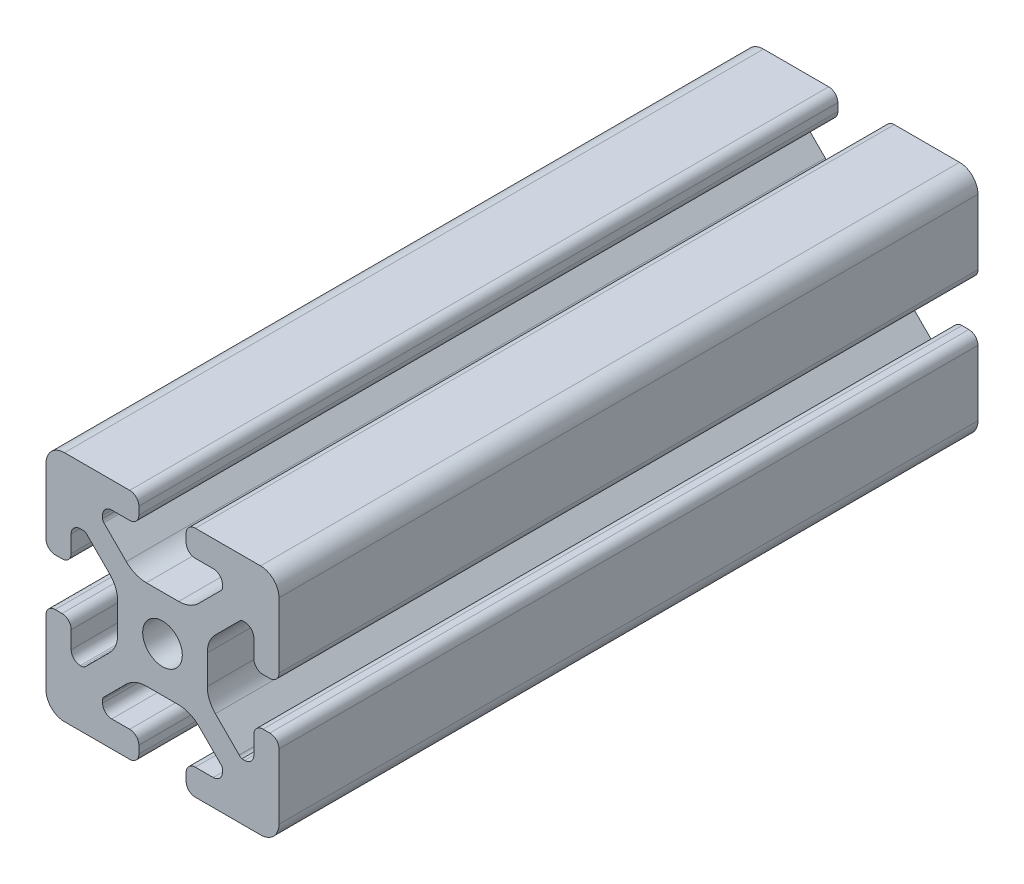
from build123d import *

# Parameters (mm, degrees)
SKETCH1_R      = 3.4
EXTRUDE1_DEPTH = 120


with BuildPart() as part:
    # Sketch1 → Extrude1 (new body)
    with BuildSketch(Plane.XY):
        with BuildLine():
            Line((-8.715, -15.524615034), (-5.63, -15.524615034))
            ThreePointArc((-5.63, -15.524615034), (-4.519842354, -15.984457388), (-4.06, -17.094615034))
            Line((-4.06, -17.094615034), (-4.06, -18.43))
            ThreePointArc((-4.06, -18.43), (-4.519842354, -19.540157646), (-5.63, -20))
            Line((-5.63, -20), (-16.674615034, -20))
            ThreePointArc((-16.674615034, -20), (-18.951578385, -19.194274381), (-20, -17.018368134))
            Line((-20, -17.018368134), (-20, -5.757918808))
            ThreePointArc((-20, -5.757918808), (-19.564709668, -4.603883664), (-18.43, -4.120449326))
            Line((-18.43, -4.120449326), (-17.25, -4.120449326))
            ThreePointArc((-17.25, -4.120449326), (-16.115287682, -4.60388249), (-15.67999625, -5.757919334))
            Line((-15.67999625, -5.757919334), (-15.67999625, -8.715399492))
            ThreePointArc((-15.67999625, -8.715399492), (-15.220153896, -9.825557139), (-14.10999625, -10.285399492))
            Line((-14.10999625, -10.285399492), (-13.816898819, -10.285399492))
            ThreePointArc((-13.816898819, -10.285399492), (-13.526061711, -10.227547119), (-13.279501941, -10.062800646))
            Line((-13.279501941, -10.062800646), (-9.076242789, -5.859541495))
            ThreePointArc((-9.076242789, -5.859541495), (-8.046572221, -4.318530588), (-7.685, -2.500784284))
            Line((-7.685, -2.500784284), (-7.685, 2.500784284))
            ThreePointArc((-7.685, 2.500784284), (-8.046572221, 4.318530588), (-9.076242789, 5.859541495))
            Line((-9.076242789, 5.859541495), (-13.040489136, 9.823787841))
            ThreePointArc((-13.040489136, 9.823787841), (-13.354224618, 10.012729352), (-13.71989919, 10.033001362))
            Line((-13.71989919, 10.033001362), (-14.05520779, 10.044710596))
            ThreePointArc((-14.05520779, 10.044710596), (-15.200613642, 9.605030484), (-15.68, 8.475666998))
            Line((-15.68, 8.475666998), (-15.68, 5.572979049))
            ThreePointArc((-15.68, 5.572979049), (-16.139842354, 4.462821403), (-17.25, 4.002979049))
            Line((-17.25, 4.002979049), (-18.43, 4.002979049))
            ThreePointArc((-18.43, 4.002979049), (-19.540157646, 4.462821403), (-20, 5.572979049))
            Line((-20, 5.572979049), (-20, 13.004526564))
            Line((-20, 13.004526564), (-20, 16.83))
            ThreePointArc((-20, 16.83), (-19.071528496, 19.071528496), (-16.83, 20))
            Line((-16.83, 20), (-5.63, 20))
            ThreePointArc((-5.63, 20), (-4.519842354, 19.540157646), (-4.06, 18.43))
            Line((-4.06, 18.43), (-4.06, 17.094615034))
            ThreePointArc((-4.06, 17.094615034), (-4.519842354, 15.984457388), (-5.63, 15.524615034))
            Line((-5.63, 15.524615034), (-8.715, 15.524615034))
            ThreePointArc((-8.715, 15.524615034), (-9.825157646, 15.06477268), (-10.285, 13.954615034))
            Line((-10.285, 13.954615034), (-10.285, 13.492503602))
            ThreePointArc((-10.285, 13.492503602), (-10.227148445, 13.201664194), (-10.062401154, 12.955102448))
            Line((-10.062401154, 12.955102448), (-6.217092793, 9.109794088))
            ThreePointArc((-6.217092793, 9.109794088), (-4.63891877, 8.055291919), (-2.777335583, 7.685))
            Line((-2.777335583, 7.685), (2.777335583, 7.685))
            ThreePointArc((2.777335583, 7.685), (4.63891877, 8.055291919), (6.217092793, 9.109794088))
            Line((6.217092793, 9.109794088), (10.062401154, 12.955102448))
            ThreePointArc((10.062401154, 12.955102448), (10.227148445, 13.201664194), (10.285, 13.492503602))
            Line((10.285, 13.492503602), (10.285, 13.954615034))
            ThreePointArc((10.285, 13.954615034), (9.825157646, 15.06477268), (8.715, 15.524615034))
            Line((8.715, 15.524615034), (5.63, 15.524615034))
            ThreePointArc((5.63, 15.524615034), (4.519842354, 15.984457388), (4.06, 17.094615034))
            Line((4.06, 17.094615034), (4.06, 18.43))
            ThreePointArc((4.06, 18.43), (4.519842354, 19.540157646), (5.63, 20))
            Line((5.63, 20), (12.979635074, 20))
            Line((12.979635074, 20), (16.83, 20))
            ThreePointArc((16.83, 20), (19.071528496, 19.071528496), (20, 16.83))
            Line((20, 16.83), (20, 13.001098436))
            Line((20, 13.001098436), (20, 5.63))
            ThreePointArc((20, 5.63), (19.540157461, 4.519842693), (18.43, 4.060000526))
            Line((18.43, 4.060000526), (17.24999625, 4.060000526))
            ThreePointArc((17.24999625, 4.060000526), (16.139838603, 4.519842879), (15.67999625, 5.630000526))
            Line((15.67999625, 5.630000526), (15.67999625, 8.715399492))
            ThreePointArc((15.67999625, 8.715399492), (15.220153896, 9.825557139), (14.10999625, 10.285399492))
            Line((14.10999625, 10.285399492), (13.816903094, 10.285399492))
            ThreePointArc((13.816903094, 10.285399492), (13.526063686, 10.227547937), (13.279501941, 10.062800646))
            Line((13.279501941, 10.062800646), (9.076242789, 5.859541495))
            ThreePointArc((9.076242789, 5.859541495), (8.046572221, 4.318530588), (7.685, 2.500784284))
            Line((7.685, 2.500784284), (7.685, -2.500784284))
            ThreePointArc((7.685, -2.500784284), (8.046572221, -4.318530588), (9.076242789, -5.859541495))
            Line((9.076242789, -5.859541495), (13.163657296, -9.946956002))
            ThreePointArc((13.163657296, -9.946956002), (13.35903797, -10.160433474), (13.6200547, -10.285399492))
            Line((13.6200547, -10.285399492), (14.10999625, -10.285399492))
            ThreePointArc((14.10999625, -10.285399492), (15.220153896, -9.825557139), (15.67999625, -8.715399492))
            Line((15.67999625, -8.715399492), (15.67999625, -5.630000526))
            ThreePointArc((15.67999625, -5.630000526), (16.139838603, -4.519842879), (17.24999625, -4.060000526))
            Line((17.24999625, -4.060000526), (18.43, -4.060000526))
            ThreePointArc((18.43, -4.060000526), (19.540157461, -4.519842693), (20, -5.63))
            Line((20, -5.63), (20, -16.83))
            ThreePointArc((20, -16.83), (19.071528496, -19.071528496), (16.83, -20))
            Line((16.83, -20), (13, -20))
            Line((13, -20), (5.63, -20))
            ThreePointArc((5.63, -20), (4.519842354, -19.540157646), (4.06, -18.43))
            Line((4.06, -18.43), (4.06, -17.094615034))
            ThreePointArc((4.06, -17.094615034), (4.519842354, -15.984457388), (5.63, -15.524615034))
            Line((5.63, -15.524615034), (8.715, -15.524615034))
            ThreePointArc((8.715, -15.524615034), (9.825157646, -15.06477268), (10.285, -13.954615034))
            Line((10.285, -13.954615034), (10.285, -13.492503602))
            ThreePointArc((10.285, -13.492503602), (10.227148445, -13.201664194), (10.062401154, -12.955102448))
            Line((10.062401154, -12.955102448), (6.217092793, -9.109794088))
            ThreePointArc((6.217092793, -9.109794088), (4.63891877, -8.055291919), (2.777335583, -7.685))
            Line((2.777335583, -7.685), (-2.777335583, -7.685))
            ThreePointArc((-2.777335583, -7.685), (-4.63891877, -8.055291919), (-6.217092793, -9.109794088))
            Line((-6.217092793, -9.109794088), (-10.062401154, -12.955102448))
            ThreePointArc((-10.062401154, -12.955102448), (-10.227148445, -13.201664194), (-10.285, -13.492503602))
            Line((-10.285, -13.492503602), (-10.285, -13.954615034))
            ThreePointArc((-10.285, -13.954615034), (-9.825157646, -15.06477268), (-8.715, -15.524615034))
        make_face()
        Circle(SKETCH1_R, mode=Mode.SUBTRACT)
    extrude(amount=-EXTRUDE1_DEPTH)


solid = part.part
